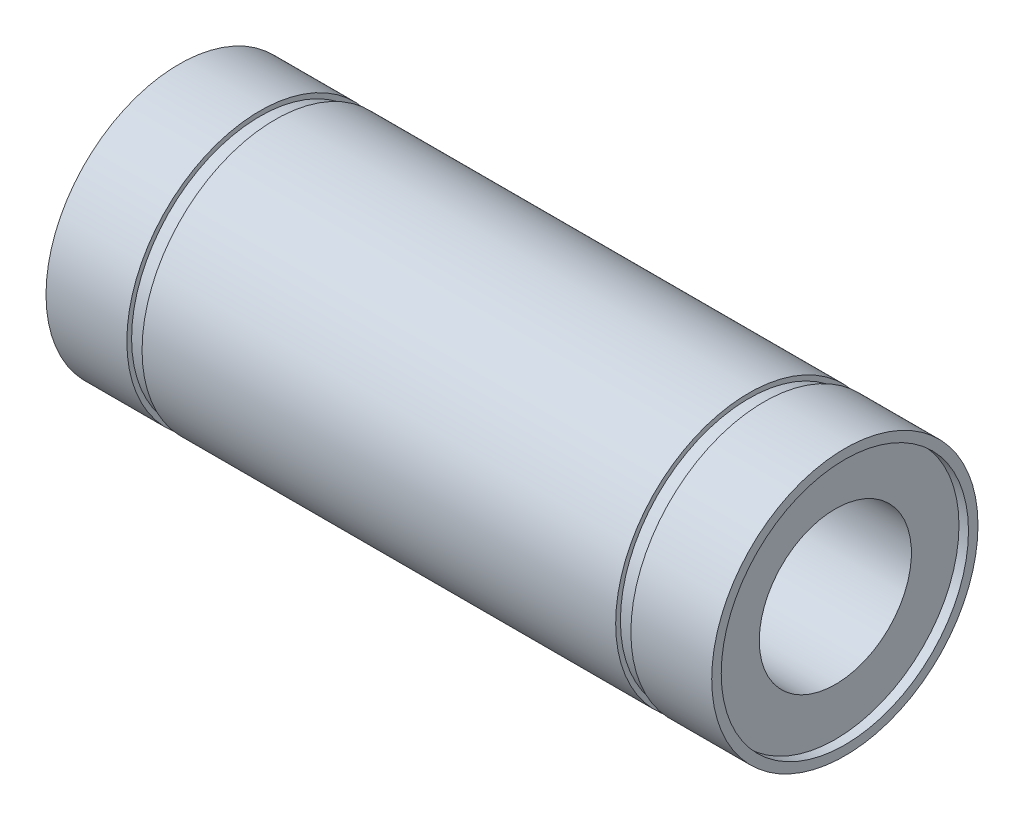
from build123d import *


with BuildPart() as part:
    # Sketch1 → Revolve2 (revolve)
    with BuildSketch(Plane.XY):
        Polygon((24.9, 14), (24.9, 13.5), (26.5, 13.5), (26.5, 14), (35, 14), (35, 13), (34, 13), (34, 8), (-34, 8), (-34, 13), (-35, 13), (-35, 14), (-26.5, 14), (-26.5, 13.5), (-24.9, 13.5), (-24.9, 14), align=None)
    revolve(axis=Axis((-35, 0, 0), (1, 0, 0)))


solid = part.part
